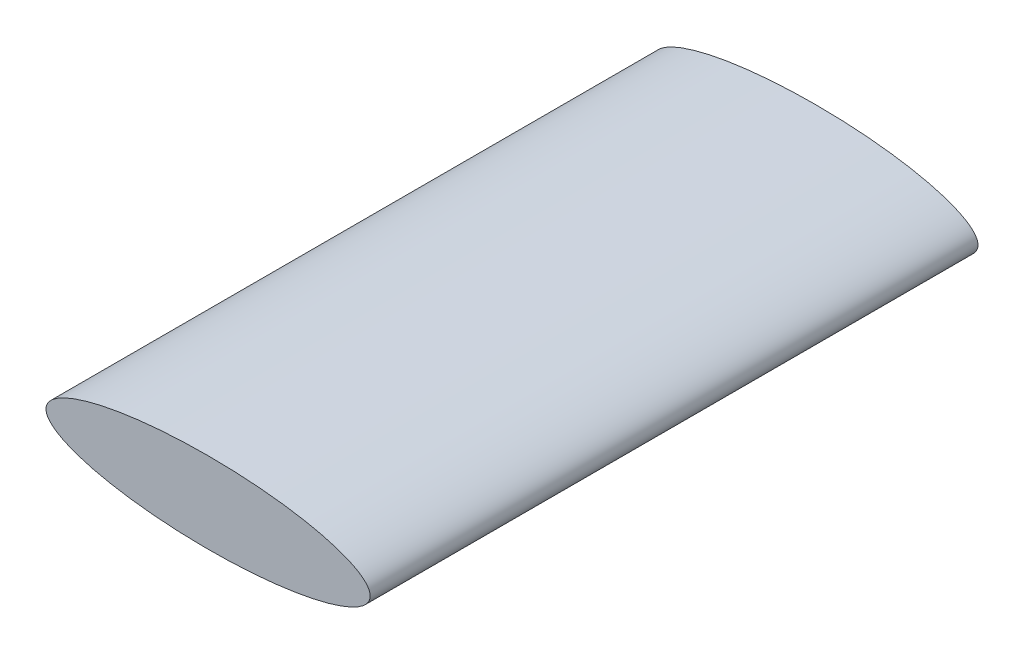
from build123d import *

# Parameters (mm, degrees)
SKETCH_1_RX     = 800
SKETCH_1_RY     = 200
EXTRUDE_1_DEPTH = 3000


with BuildPart() as part:
    # Эскиз1 → Вытянуть1 (new body)
    with BuildSketch(Plane.XY):
        with Locations(Location((1000, 400), (0, 0, 180))):
            Ellipse(SKETCH_1_RX, SKETCH_1_RY)
    extrude(amount=-EXTRUDE_1_DEPTH)


solid = part.part
